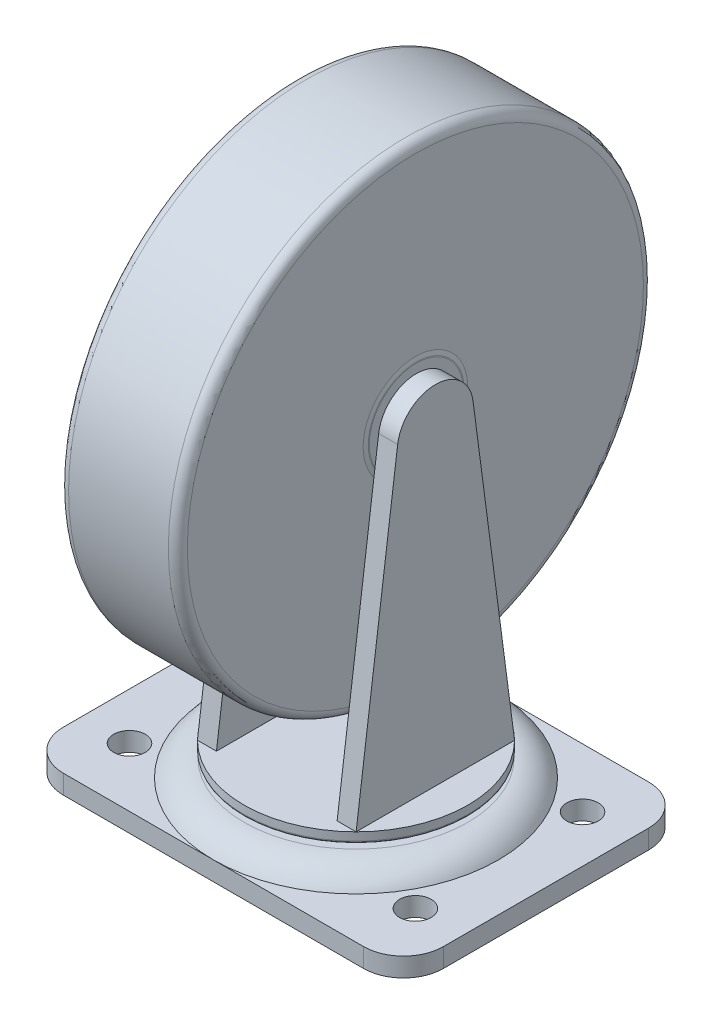
from build123d import *

# Parameters (mm, degrees)
SKETCH1_R               = 4.2164
MOUNTING_PLATE_MP_DEPTH = 5.08
WHEEL_SUPPORT_1_DEPTH   = 5.08
FILLET1_R               = 2.54
FILLET2_R               = 0.635


with BuildPart() as part:
    # Sketch1 → Mounting Plate (MP) (new body)
    with BuildSketch(Plane(origin=(0, 0, 0), x_dir=(1, 0, 0), z_dir=(0, 1, 0))):
        with BuildLine():
            Line((-40.132, 38.1), (40.132, 38.1))
            ThreePointArc((40.132, 38.1), (47.675415142, 34.975415142), (50.8, 27.432))
            Line((50.8, 27.432), (50.8, -27.432))
            ThreePointArc((50.8, -27.432), (47.675415142, -34.975415142), (40.132, -38.1))
            Line((40.132, -38.1), (-40.132, -38.1))
            ThreePointArc((-40.132, -38.1), (-47.675415142, -34.975415142), (-50.8, -27.432))
            Line((-50.8, -27.432), (-50.8, 27.432))
            ThreePointArc((-50.8, 27.432), (-47.675415142, 34.975415142), (-40.132, 38.1))
        make_face()
        with Locations((38.2143, 22.3393)):
            Circle(SKETCH1_R, mode=Mode.SUBTRACT)
        with Locations((-38.2143, 22.3393)):
            Circle(SKETCH1_R, mode=Mode.SUBTRACT)
        with Locations((-38.2143, -22.3393)):
            Circle(SKETCH1_R, mode=Mode.SUBTRACT)
        with Locations((38.2143, -22.3393)):
            Circle(SKETCH1_R, mode=Mode.SUBTRACT)
    extrude(amount=MOUNTING_PLATE_MP_DEPTH)

    # Sketch2 → MP Bearing Retainer (revolve)
    with BuildSketch(Plane.XY):
        with BuildLine():
            Line((0, 9.652), (-29.893008834, 9.652))
            ThreePointArc((-29.893008834, 9.652), (-34.590292304, 8.431881878), (-38.1, 5.08))
            Line((-38.1, 5.08), (0, 5.08))
            Line((0, 5.08), (0, 9.652))
        make_face()
    revolve(axis=Axis((0, 5.08, 0), (0, 1, 0)))

    # Sketch3 → Caster Wheel Base (revolve)
    with BuildSketch(Plane.XY):
        Polygon((0, 9.652), (-6.35, 9.652), (-6.35, 10.922), (-29.972, 10.922), (-29.972, 13.716), (0, 13.716), align=None)
    revolve(axis=Axis((0, 13.716, 0), (0, -1, 0)))

    # Sketch7 → Wheel Support 1 (add)
    with BuildSketch(Plane.ZY.offset(-21.209)):
        with BuildLine():
            Line((10.072633417, 97.849532267), (21.177797407, 13.716))
            Line((21.177797407, 13.716), (-21.177797407, 13.716))
            Line((-21.177797407, 13.716), (-10.072633417, 97.849532267))
            ThreePointArc((-10.072633417, 97.849532267), (0, 106.68), (10.072633417, 97.849532267))
        make_face()
    wheel_support_1 = extrude(amount=WHEEL_SUPPORT_1_DEPTH)

    # Wheel Support 2: Wheel Support 1 across plane
    add(wheel_support_1.mirror(Plane.ZY))

    # Sketch9 → Revolve3 (revolve)
    with BuildSketch(Plane(origin=(0, 96.52, 0), x_dir=(1, 0, 0), z_dir=(0, 1, 0))):
        with BuildLine():
            Line((-16.129, 0), (16.129, 0))
            Line((16.129, 0), (16.129, 12.574245218))
            ThreePointArc((16.129, 12.574245218), (16.122819325, 12.699387993), (16.104337458, 12.823312709))
            Line((16.104337458, 12.823312709), (15.875, 13.97))
            Line((15.875, 13.97), (15.875, 63.5))
            Line((15.875, 63.5), (-15.875, 63.5))
            Line((-15.875, 63.5), (-15.875, 13.97))
            Line((-15.875, 13.97), (-16.104337458, 12.823312709))
            ThreePointArc((-16.104337458, 12.823312709), (-16.122819325, 12.699387993), (-16.129, 12.574245218))
            Line((-16.129, 12.574245218), (-16.129, 0))
        make_face()
    revolve(axis=Axis((-16.129, 96.52, 0), (1, 0, 0)))

    # Fillet1
    fillet1_edges = [part.edges().sort_by_distance(p)[0] for p in [
        (15.875, 96.52, 63.5),
        (-15.875, 96.52, 63.5),
    ]]
    fillet(fillet1_edges, radius=FILLET1_R)

    # Fillet2
    fillet2_edges = [part.edges().sort_by_distance(p)[0] for p in [
        (29.972, 10.922, 0),
    ]]
    fillet(fillet2_edges, radius=FILLET2_R)


solid = part.part
